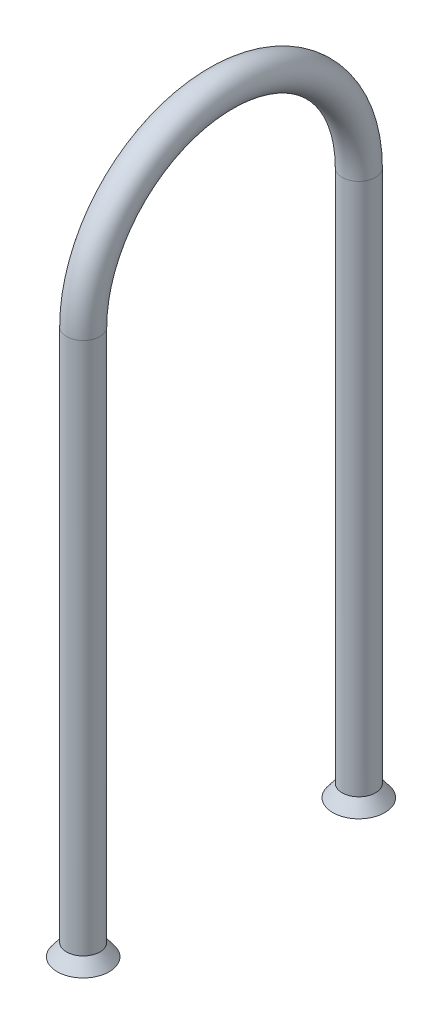
from build123d import *

# Parameters (mm, degrees)
SKETCH8_R           = 2.38125
SKETCH8_R_2         = 1.82245
SKETCH10_R          = 2.38125
BOSS_EXTRUDE3_DEPTH = 1.778
BOSS_EXTRUDE3_TAPER = -37
SKETCH11_R          = 1.82245
CUT_EXTRUDE2_DEPTH  = 2.7780001
CUT_EXTRUDE2_TAPER  = -37


with BuildPart() as part:
    # Sweep2: sweep along a path in Sketch9
    with BuildLine(Plane(origin=(0, 0, 0), x_dir=(0, 0, -1), z_dir=(1, 0, 0))) as sweep2_path:
        Line((-19.702223994, -95.902223994), (-19.702223994, -19.702223994))
        ThreePointArc((-19.702223994, -19.702223994), (-13.931576191, -5.770647803), (0, 0))
    # Sketch8 → Sweep2 (sweep)
    with BuildSketch(Plane.XY):
        Circle(SKETCH8_R)
        Circle(SKETCH8_R_2, mode=Mode.SUBTRACT)
    sweep2 = sweep(path=sweep2_path.line)

    # Sketch10 → Boss-Extrude3 (add)
    with BuildSketch(Plane.XZ.offset(95.902223994)):
        with Locations((0, 19.702223994)):
            Circle(SKETCH10_R)
    boss_extrude3 = extrude(amount=BOSS_EXTRUDE3_DEPTH, taper=BOSS_EXTRUDE3_TAPER)

    # Sketch11 → Cut-Extrude2 (cut, through all)
    with BuildSketch(Plane(origin=(0, -95.902223994, 0), x_dir=(1, 0, 0), z_dir=(0, 1, 0))):
        with Locations(Location((0, -19.702223994, 0), (0, 0, 270))):  # turned: the seam where the file's is
            Circle(SKETCH11_R)
    cut_extrude2 = extrude(amount=-CUT_EXTRUDE2_DEPTH, taper=CUT_EXTRUDE2_TAPER, mode=Mode.SUBTRACT)

    # Mirror1: Sweep2, Boss-Extrude3, Cut-Extrude2 across plane
    add(sweep2.mirror(Plane.XY))
    add(boss_extrude3.mirror(Plane.XY))
    add(cut_extrude2.mirror(Plane.XY), mode=Mode.SUBTRACT)


solid = part.part
